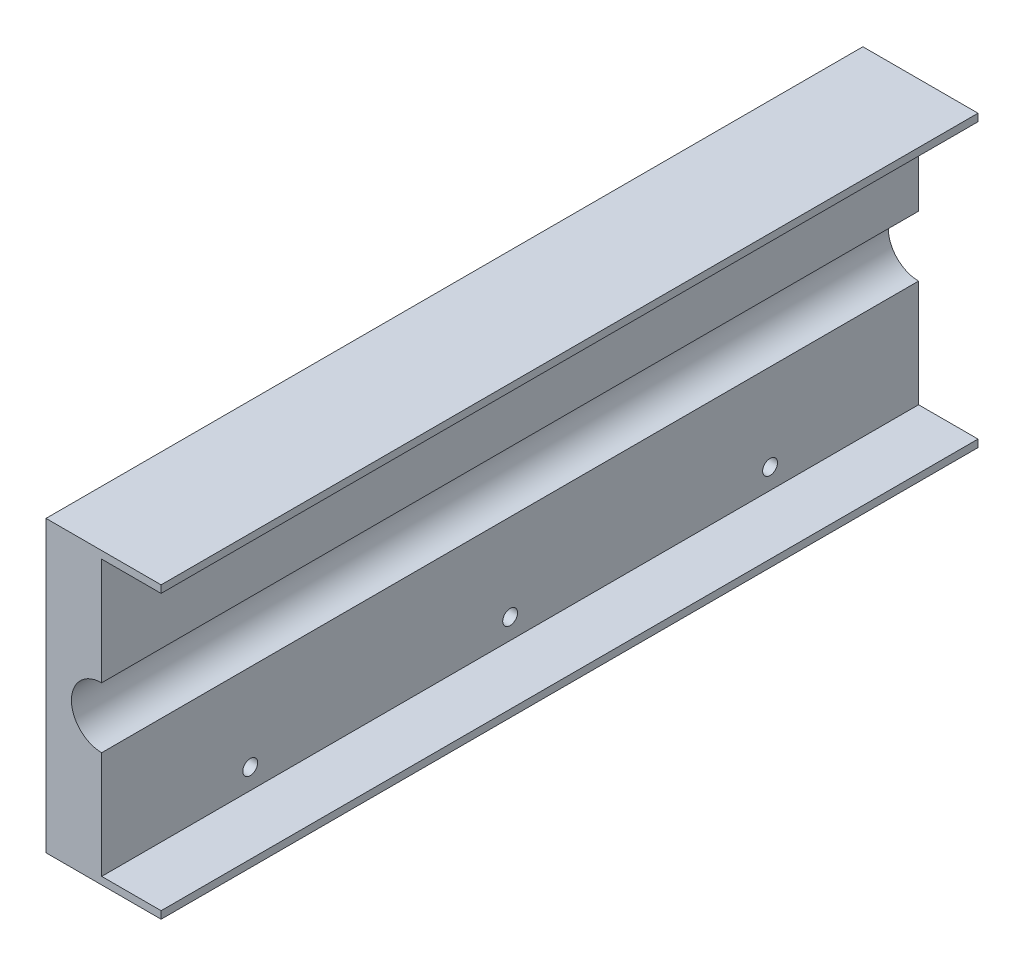
from build123d import *

# Parameters (mm, degrees)
SALIENTE_EXTRUIR1_DEPTH   = 220
CROQUIS5_R                = 2
CORTAR_EXTRUIR5_DEPTH     = 20
CROQUIS7_W                = 220
CROQUIS7_H                = 2
SALIENTE_EXTRUIR2_DEPTH   = 16
SALIENTE_EXTRUIR2_2_DEPTH = 16
CROQUIS7_3_W              = 220
CROQUIS7_3_H              = 2
SALIENTE_EXTRUIR3_DEPTH   = 15


with BuildPart() as part:
    # Croquis1 → Saliente-Extruir1 (new body)
    with BuildSketch(Plane.XY):
        with BuildLine():
            Line((0, 37), (0, 8.15))
            ThreePointArc((0, 8.15), (-8.15, 0), (0, -8.15))
            Line((0, -8.15), (0, -37))
            Line((0, -37), (-15, -37))
            Line((-15, -37), (-15, 37))
            Line((-15, 37), (0, 37))
        make_face()
    extrude(amount=SALIENTE_EXTRUIR1_DEPTH)

    # Croquis5 → Cortar-Extruir5 (cut)
    with BuildSketch(Plane.ZY.offset(15)):
        with Locations((110, -31.5)):
            Circle(CROQUIS5_R)
        with Locations((110, 31.5)):
            Circle(CROQUIS5_R)
        with Locations((40, 31.5)):
            Circle(CROQUIS5_R)
        with Locations((40, -31.5)):
            Circle(CROQUIS5_R)
        with Locations((180, 31.5)):
            Circle(CROQUIS5_R)
        with Locations((180, -31.5)):
            Circle(CROQUIS5_R)
    extrude(amount=-CORTAR_EXTRUIR5_DEPTH, mode=Mode.SUBTRACT)



with BuildPart() as body_2:
    # Croquis7 → Saliente-Extruir2 (new body)
    with BuildSketch(Plane(origin=(0, 0, 0), x_dir=(0, 0, -1), z_dir=(1, 0, 0))):
        with Locations((-110, -38)):
            Rectangle(CROQUIS7_W, CROQUIS7_H)
    extrude(amount=SALIENTE_EXTRUIR2_DEPTH)


with BuildPart() as body_3:
    # Croquis7 → Saliente-Extruir2 2 (new body)
    with BuildSketch(Plane(origin=(0, 0, 0), x_dir=(0, 0, -1), z_dir=(1, 0, 0))):
        with Locations((-110, 38)):
            Rectangle(CROQUIS7_W, CROQUIS7_H)
    extrude(amount=SALIENTE_EXTRUIR2_2_DEPTH)


with BuildPart() as part_1:
    add(part.part)

    add(body_2.part)  # Saliente-Extruir3 merges body 2

    add(body_3.part)  # Saliente-Extruir3 merges body 3
    # Croquis7_3 → Saliente-Extruir3 (add)
    with BuildSketch(Plane(origin=(0, 0, 0), x_dir=(0, 0, -1), z_dir=(1, 0, 0))):
        with Locations((-110, -38)):
            Rectangle(CROQUIS7_3_W, CROQUIS7_3_H)
        with Locations((-110, 38)):
            Rectangle(CROQUIS7_3_W, CROQUIS7_3_H)
    extrude(amount=-SALIENTE_EXTRUIR3_DEPTH)


solid = part_1.part
